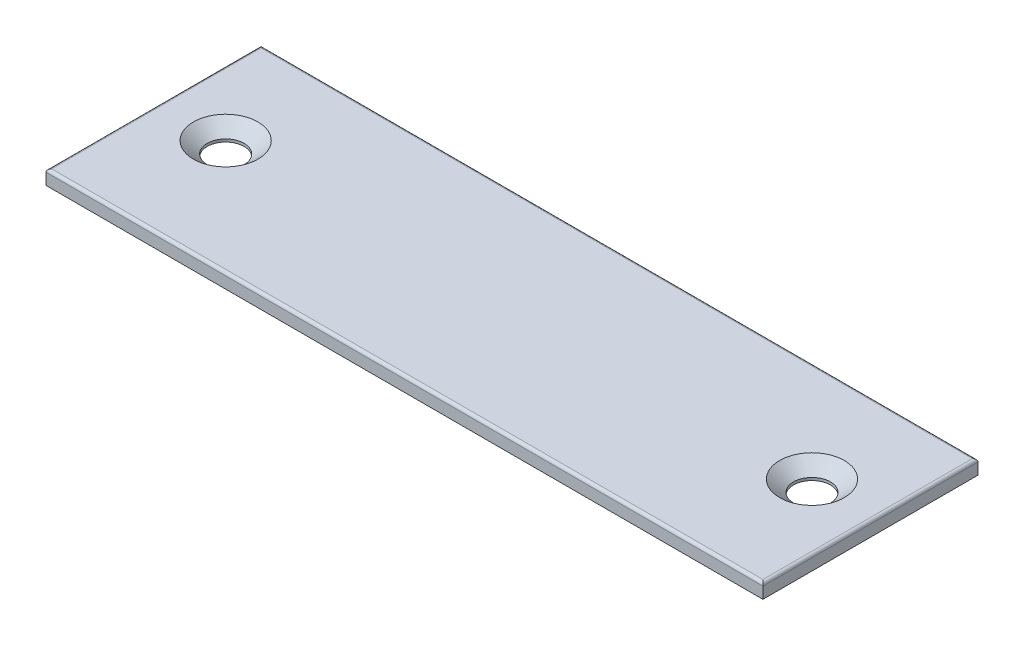
from build123d import *

# Parameters (mm, degrees)
SKETCH1_W                                 = 63.5
SKETCH1_H                                 = 19.05
BOSS_EXTRUDE1_DEPTH                       = 1.27
CSK_FOR_4_FLAT_HEAD_MACHINE_SCREW_2_COUNT = 2
CSK_FOR_4_FLAT_HEAD_MACHINE_SCREW_2_PITCH = 51.93240976
FILLET2_R                                 = 0.254


with BuildPart() as part:
    # Sketch1 → Boss-Extrude1 (new body)
    with BuildSketch(Plane(origin=(0, 0, 0), x_dir=(1, 0, 0), z_dir=(0, 1, 0))):
        with Locations((0, 21.324911643)):
            Rectangle(SKETCH1_W, SKETCH1_H)
    extrude(amount=BOSS_EXTRUDE1_DEPTH)

    # Sketch15 → CSK for #4 Flat Head Machine Screw (100)2 (revolve, cut)
    with BuildSketch(Plane(origin=(-25.96620488, 1.27, -21.930009473), x_dir=(0, 0, 1), z_dir=(1, 0, 0))):
        Polygon((0, 0), (0, 1.27), (1.63195, 1.27), (1.63195, 1.028358553), (2.8575, 0), align=None)
    csk_for_4_flat_head_machine_screw_100 = revolve(axis=Axis((-25.96620488, 7.62, -21.930009473), (0, -1, 0)), mode=Mode.SUBTRACT)

    # CSK for _4 Flat Head Machine Screw _ 2: CSK for #4 Flat Head Machine Screw (100)2 ×2
    with Locations(*[(i * CSK_FOR_4_FLAT_HEAD_MACHINE_SCREW_2_PITCH, 0, 0) for i in range(1, CSK_FOR_4_FLAT_HEAD_MACHINE_SCREW_2_COUNT)]):
        add(csk_for_4_flat_head_machine_screw_100, mode=Mode.SUBTRACT)

    # Fillet2
    fillet2_edges = [part.edges().sort_by_distance(p)[0] for p in [
        (-31.75, 1.27, -21.324911643),
        (0, 1.27, -11.799911643),
        (31.75, 1.27, -21.324911643),
        (0, 1.27, -30.849911643),
    ]]
    fillet(fillet2_edges, radius=FILLET2_R)


solid = part.part
